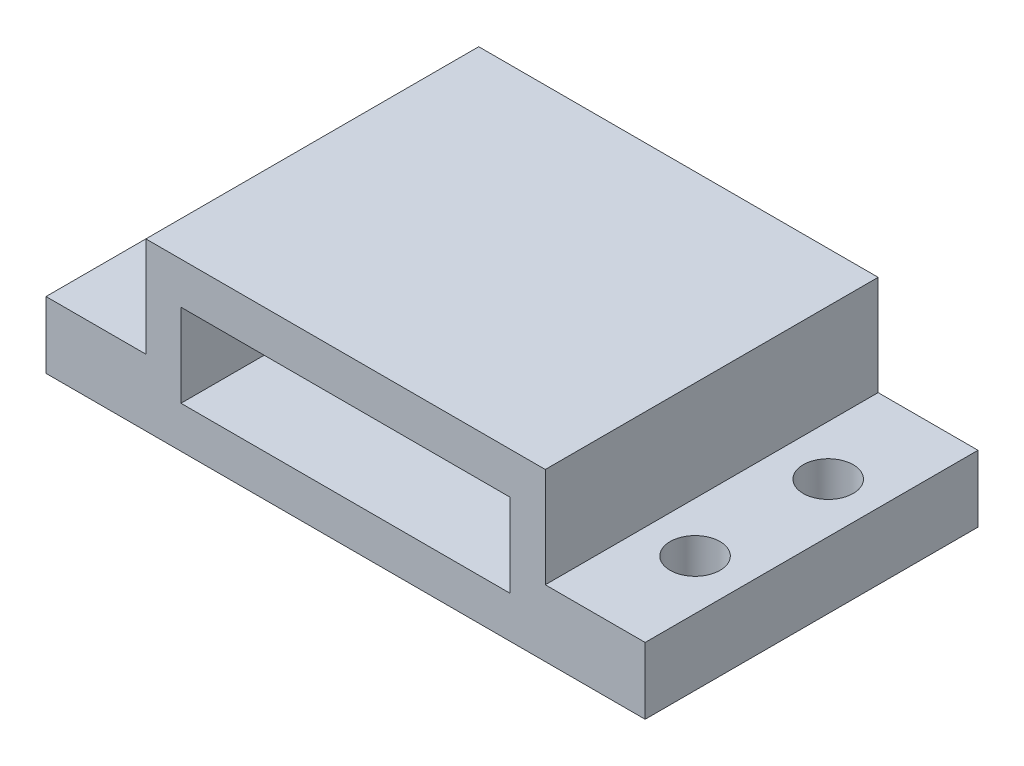
from build123d import *

# Parameters (mm, degrees)
SKETCH2_W           = 6
SKETCH2_H           = 10
BOSS_EXTRUDE2_DEPTH = 5
SKETCH4_W           = 4.945
SKETCH4_H           = 2.5
CUT_EXTRUDE1_DEPTH  = 8
SKETCH6_W           = 3.25
SKETCH6_H           = 0.5
CUT_EXTRUDE2_DEPTH  = 8
SKETCH7_W           = 10
SKETCH7_H           = 1.999993684
BOSS_EXTRUDE3_DEPTH = 3
SKETCH8_W           = 10
SKETCH8_H           = 2
BOSS_EXTRUDE4_DEPTH = 3
SKETCH11_R          = 0.75
CUT_EXTRUDE7_DEPTH  = 3


with BuildPart() as part:
    # Sketch2 → Boss-Extrude2 (new body)
    with BuildSketch(Plane(origin=(0, 0, 0), x_dir=(1, 0, 0), z_dir=(0, 1, 0))):
        with Locations((-3, 5)):
            Rectangle(SKETCH2_W, SKETCH2_H)
        with Locations((3, 5)):
            Rectangle(SKETCH2_W, SKETCH2_H)
    extrude(amount=BOSS_EXTRUDE2_DEPTH)

    # Sketch4 → Cut-Extrude1 (cut)
    with BuildSketch(Plane.XY):
        with Locations((-2.4725, 2.5)):
            Rectangle(SKETCH4_W, SKETCH4_H)
        with Locations((2.4725, 2.5)):
            Rectangle(SKETCH4_W, SKETCH4_H)
    extrude(amount=-CUT_EXTRUDE1_DEPTH, mode=Mode.SUBTRACT)

    # Sketch6 → Cut-Extrude2 (cut)
    with BuildSketch(Plane(origin=(0, 0, -10), x_dir=(-1, 0, 0), z_dir=(0, 0, -1))):
        with Locations((-1.625, 2.5)):
            Rectangle(SKETCH6_W, SKETCH6_H)
        with Locations((1.625, 2.5)):
            Rectangle(SKETCH6_W, SKETCH6_H)
    extrude(amount=-CUT_EXTRUDE2_DEPTH, mode=Mode.SUBTRACT)

    # Sketch7 → Boss-Extrude3 (add)
    with BuildSketch(Plane.ZY.offset(6)):
        with Locations((-5, 0.999996842)):
            Rectangle(SKETCH7_W, SKETCH7_H)
    extrude(amount=BOSS_EXTRUDE3_DEPTH)

    # Sketch8 → Boss-Extrude4 (add)
    with BuildSketch(Plane(origin=(6, 0, 0), x_dir=(0, 0, -1), z_dir=(1, 0, 0))):
        with Locations((5, 1)):
            Rectangle(SKETCH8_W, SKETCH8_H)
    extrude(amount=BOSS_EXTRUDE4_DEPTH)

    # Sketch11 → Cut-Extrude7 (cut)
    with BuildSketch(Plane(origin=(0, 2, 0), x_dir=(1, 0, 0), z_dir=(0, 1, 0))):
        with Locations((-7.5, 7)):
            Circle(SKETCH11_R)
        with Locations((-7.5, 3)):
            Circle(SKETCH11_R)
        with Locations((7.5, 3)):
            Circle(SKETCH11_R)
        with Locations((7.5, 7)):
            Circle(SKETCH11_R)
    extrude(amount=-CUT_EXTRUDE7_DEPTH, mode=Mode.SUBTRACT)


solid = part.part
